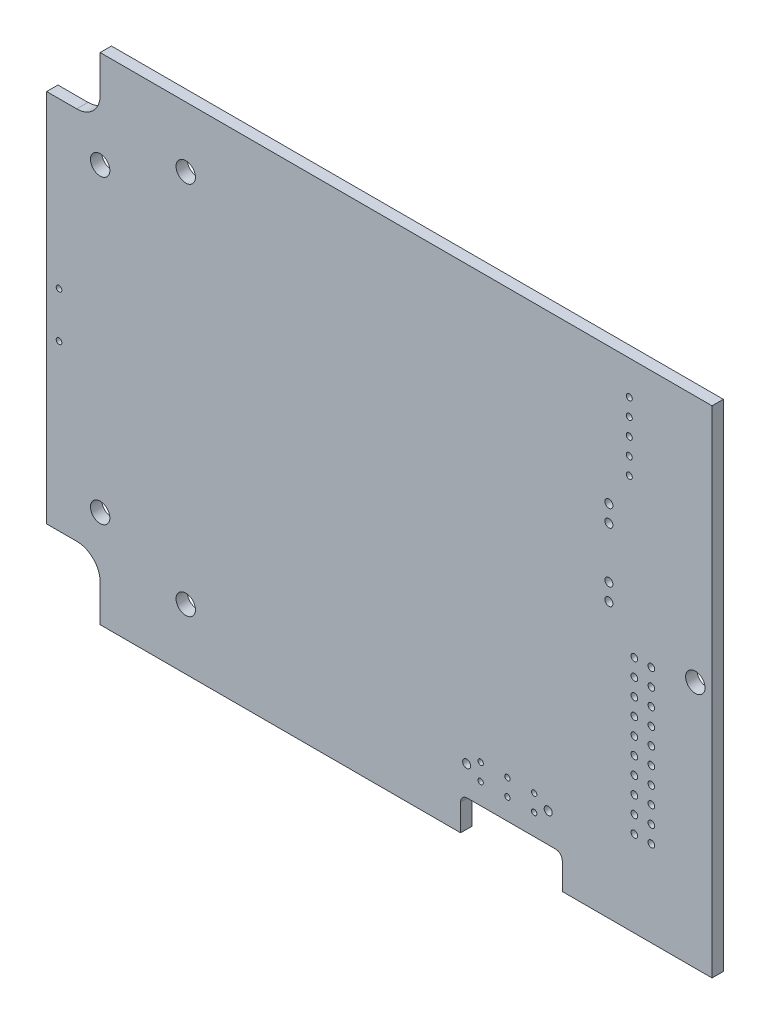
from build123d import *

# Parameters (mm, degrees)
BOSS_EXTRUDE1_DEPTH          = 1.68939972
F_2_9_2_9_DIAMETER_HOLE1_D   = 2.89999928
HOLE1_D                      = 0.8999982
LPATTERN1_COUNT              = 5
LPATTERN1_PITCH              = 2.54
HOLE2_D                      = 0.999998
LPATTERN2_COUNT              = 2
LPATTERN2_PITCH              = 2.54
LPATTERN2_COUNT_DIR2         = 10
LPATTERN2_PITCH_DIR2         = 2.54
HOLE3_D                      = 1.1999976
LPATTERN3_COUNT              = 2
LPATTERN3_PITCH              = 2.540004919
HOLE4_D                      = 1.1999976
LPATTERN4_COUNT              = 2
LPATTERN4_PITCH              = 2.540004919
F_2_9_2_9_DIAMETER_HOLE2_D   = 2.89999928
F_2_9_2_9_DIAMETER_HOLE3_D   = 2.89999928
F_0_85_0_85_DIAMETER_HOLE1_D = 0.85000084
LPATTERN5_COUNT              = 2
LPATTERN5_PITCH              = 6.80000164
HOLE5_D                      = 0.7999984
LPATTERN6_COUNT              = 3
LPATTERN6_PITCH              = 3.99999962
LPATTERN6_COUNT_DIR2         = 2
LPATTERN6_PITCH_DIR2         = 2.50000008
F_2_9_2_9_DIAMETER_HOLE4_D   = 2.89999928
HOLE6_D                      = 1.1999976
LPATTERN7_COUNT              = 2
LPATTERN7_PITCH              = 12.200001
F_2_9_2_9_DIAMETER_HOLE5_D   = 2.89999928


with BuildPart() as part:
    # Sketch1 → Boss-Extrude1 (new body)
    with BuildSketch(Plane.XY.offset(1.68939972)):
        with BuildLine():
            Line((87.300003052, 25.399999619), (87.300003052, 29.399999619))
            ThreePointArc((87.300003052, 29.399999619), (87.592896271, 30.1071064), (88.300003052, 30.399999619))
            Line((88.300003052, 30.399999619), (101.5, 30.399999619))
            ThreePointArc((101.5, 30.399999619), (102.207106781, 30.1071064), (102.5, 29.399999619))
            Line((102.5, 29.399999619), (102.5, 25.399999619))
            Line((102.5, 25.399999619), (124.900001526, 25.399999619))
            Line((124.900001526, 25.399999619), (124.900001526, 99.5))
            Line((124.900001526, 99.5), (33.400001526, 99.5))
            Line((33.400001526, 99.5), (33.400001526, 93.949998856))
            ThreePointArc((33.400001526, 93.949998856), (32.374874701, 91.475123773), (29.899999619, 90.449996948))
            Line((29.899999619, 90.449996948), (25.399999619, 90.449996948))
            Line((25.399999619, 90.449996948), (25.399999619, 34.450000763))
            Line((25.399999619, 34.450000763), (29.899999619, 34.450000763))
            ThreePointArc((29.899999619, 34.450000763), (32.374874701, 33.424873938), (33.400001526, 30.949998856))
            Line((33.400001526, 30.949998856), (33.400001526, 25.399999619))
            Line((33.400001526, 25.399999619), (87.300003052, 25.399999619))
        make_face()
    extrude(amount=-BOSS_EXTRUDE1_DEPTH)

    # Ø2.9 (2.9) Diameter Hole1 (through all)
    with Locations(Plane(origin=(0, 0, 0), x_dir=(-1, 0, 0), z_dir=(0, 0, -1))):
        with Locations((-122.39998888, 62.44998432)):
            Hole(F_2_9_2_9_DIAMETER_HOLE1_D / 2)

    # Hole1 (through all)
    with Locations(Plane(origin=(0, 0, 0), x_dir=(-1, 0, 0), z_dir=(0, 0, -1))):
        with Locations((-112.52199746, 94.4230014)):
            hole1 = Hole(HOLE1_D / 2)

    # LPattern1: Hole1 ×5
    with Locations(*[(0, -i * LPATTERN1_PITCH, 0) for i in range(1, LPATTERN1_COUNT)]):
        add(hole1, mode=Mode.SUBTRACT)

    # Hole2 (through all)
    with Locations(Plane(origin=(0, 0, 0), x_dir=(-1, 0, 0), z_dir=(0, 0, -1))):
        with Locations((-113.284, 38.227)):
            hole2 = Hole(HOLE2_D / 2)

    # LPattern2: Hole2 2 × 10
    with Locations(*[(i * LPATTERN2_PITCH, j * LPATTERN2_PITCH_DIR2, 0) for i in range(LPATTERN2_COUNT) for j in range(LPATTERN2_COUNT_DIR2) if (i, j) != (0, 0)]):
        add(hole2, mode=Mode.SUBTRACT)

    # Hole3 (through all)
    with Locations(Plane(origin=(0, 0, 0), x_dir=(-1, 0, 0), z_dir=(0, 0, -1))):
        with Locations((-109.47899872, 79.121)):
            hole3 = Hole(HOLE3_D / 2)

    # LPattern3: Hole3 ×2
    with Locations(*[Vector(-0.0019679961889539077, -0.9999980634936251, 0) * (i * LPATTERN3_PITCH) for i in range(1, LPATTERN3_COUNT)]):
        add(hole3, mode=Mode.SUBTRACT)

    # Hole4 (through all)
    with Locations(Plane(origin=(0, 0, 0), x_dir=(-1, 0, 0), z_dir=(0, 0, -1))):
        with Locations((-109.47899872, 68.961)):
            hole4 = Hole(HOLE4_D / 2)

    # LPattern4: Hole4 ×2
    with Locations(*[Vector(-0.0019679961889539077, -0.9999980634936251, 0) * (i * LPATTERN4_PITCH) for i in range(1, LPATTERN4_COUNT)]):
        add(hole4, mode=Mode.SUBTRACT)

    # Ø2.9 (2.9) Diameter Hole2 (through all)
    with Locations(Plane(origin=(0, 0, 0), x_dir=(-1, 0, 0), z_dir=(0, 0, -1))):
        with Locations((-46.1999838, 90.44998928)):
            Hole(F_2_9_2_9_DIAMETER_HOLE2_D / 2)

    # Ø2.9 (2.9) Diameter Hole3 (through all)
    with Locations(Plane(origin=(0, 0, 0), x_dir=(-1, 0, 0), z_dir=(0, 0, -1))):
        with Locations((-33.399984, 84.94998504)):
            Hole(F_2_9_2_9_DIAMETER_HOLE3_D / 2)

    # Ø0.85 (0.85) Diameter Hole1 (through all)
    with Locations(Plane(origin=(0, 0, 0), x_dir=(-1, 0, 0), z_dir=(0, 0, -1))):
        with Locations((-27.25008266, 65.84998768)):
            f_0_85_0_85_diameter_hole1 = Hole(F_0_85_0_85_DIAMETER_HOLE1_D / 2)

    # LPattern5: Ø0.85 (0.85) Diameter Hole1 ×2
    with Locations(*[(0, -i * LPATTERN5_PITCH, 0) for i in range(1, LPATTERN5_COUNT)]):
        add(f_0_85_0_85_diameter_hole1, mode=Mode.SUBTRACT)

    # Hole5 (through all)
    with Locations(Plane(origin=(0, 0, 0), x_dir=(-1, 0, 0), z_dir=(0, 0, -1))):
        with Locations((-90.29998196, 36.04998632)):
            hole5 = Hole(HOLE5_D / 2)

    # LPattern6: Hole5 3 × 2
    with Locations(*[(i * LPATTERN6_PITCH, -j * LPATTERN6_PITCH_DIR2, 0) for i in range(LPATTERN6_COUNT) for j in range(LPATTERN6_COUNT_DIR2) if (i, j) != (0, 0)]):
        add(hole5, mode=Mode.SUBTRACT)

    # Ø2.9 (2.9) Diameter Hole4 (through all)
    with Locations(Plane(origin=(0, 0, 0), x_dir=(-1, 0, 0), z_dir=(0, 0, -1))):
        with Locations((-46.1999838, 34.44998952)):
            Hole(F_2_9_2_9_DIAMETER_HOLE4_D / 2)

    # Hole6 (through all)
    with Locations(Plane(origin=(0, 0, 0), x_dir=(-1, 0, 0), z_dir=(0, 0, -1))):
        with Locations((-88.19998108, 34.79998628)):
            hole6 = Hole(HOLE6_D / 2)

    # LPattern7: Hole6 ×2
    with Locations(*[(i * LPATTERN7_PITCH, 0, 0) for i in range(1, LPATTERN7_COUNT)]):
        add(hole6, mode=Mode.SUBTRACT)

    # Ø2.9 (2.9) Diameter Hole5 (through all)
    with Locations(Plane(origin=(0, 0, 0), x_dir=(-1, 0, 0), z_dir=(0, 0, -1))):
        with Locations((-33.399984, 39.9499836)):
            Hole(F_2_9_2_9_DIAMETER_HOLE5_D / 2)


solid = part.part
